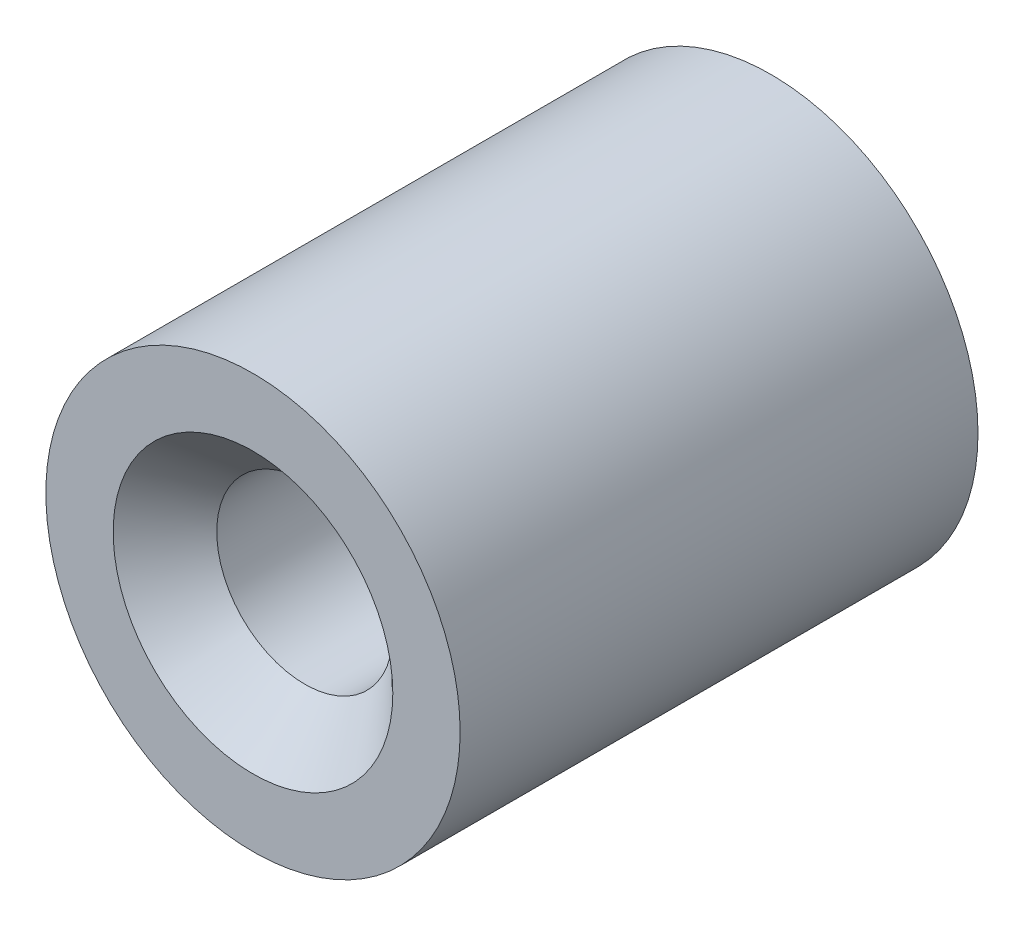
from build123d import *

# Parameters (mm, degrees)
SKETCH_1_R        = 8
EXTRUDE_1_DEPTH   = 20
HOLE_WIZARD_M81_D = 6.8
CHAMFER_1_SIZE    = 2


with BuildPart() as part:
    # Эскиз1 → Бобышка-Вытянуть1 (new body)
    with BuildSketch(Plane.XY):
        Circle(SKETCH_1_R)
    extrude(amount=EXTRUDE_1_DEPTH)

    # Отверстие обработанное метчиком M81 (through all)
    with Locations(Plane.XY.offset(20)):
        with Locations((0, 0)):
            Hole(HOLE_WIZARD_M81_D / 2)

    # Фаска1
    chamfer_1_edges = [part.edges().sort_by_distance(p)[0] for p in [
        (3.4, 0, 20),
    ]]
    chamfer(chamfer_1_edges, length=CHAMFER_1_SIZE)


solid = part.part
